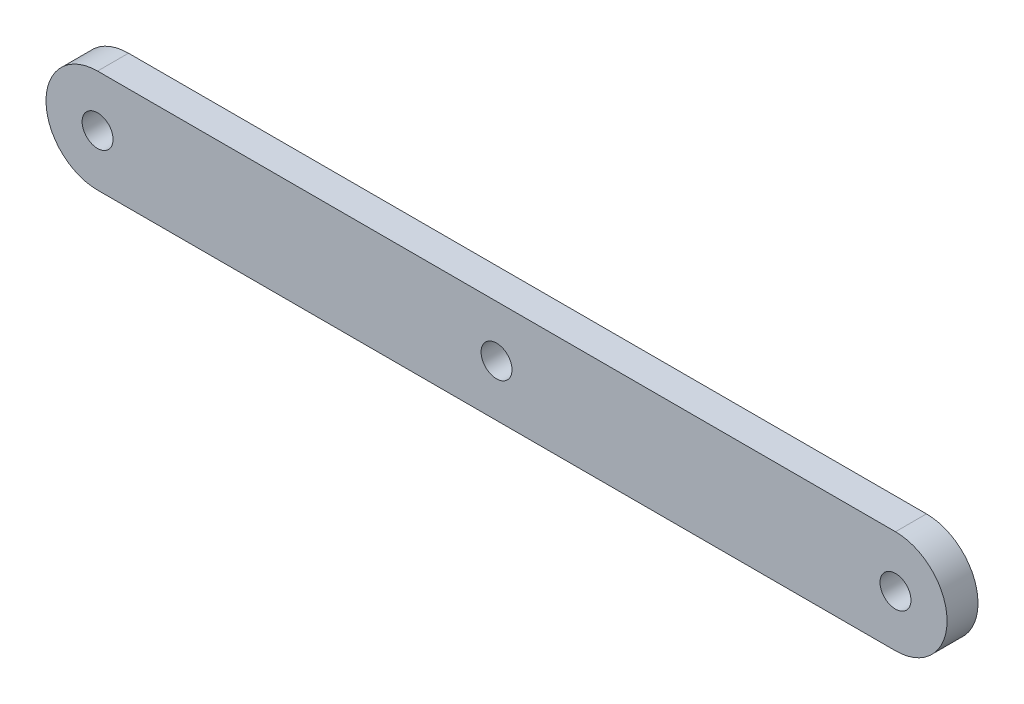
from build123d import *

# Parameters (mm, degrees)
SKETCH_1_R      = 0.75
EXTRUDE_1_DEPTH = 0.75


with BuildPart() as part:
    # 草圖1 → 填料-伸長1 (new body, symmetric)
    with BuildSketch(Plane.XY):
        with BuildLine():
            Line((-19.3421, 2.5), (19.3421, 2.5))
            ThreePointArc((19.3421, 2.5), (21.8421, 0), (19.3421, -2.5))
            Line((19.3421, -2.5), (-19.3421, -2.5))
            ThreePointArc((-19.3421, -2.5), (-21.8421, 0), (-19.3421, 2.5))
        make_face()
        with Locations((-19.3421, 0)):
            Circle(SKETCH_1_R, mode=Mode.SUBTRACT)
        with Locations((19.3421, 0)):
            Circle(SKETCH_1_R, mode=Mode.SUBTRACT)
        Circle(SKETCH_1_R, mode=Mode.SUBTRACT)
    extrude(amount=EXTRUDE_1_DEPTH, both=True)


solid = part.part
